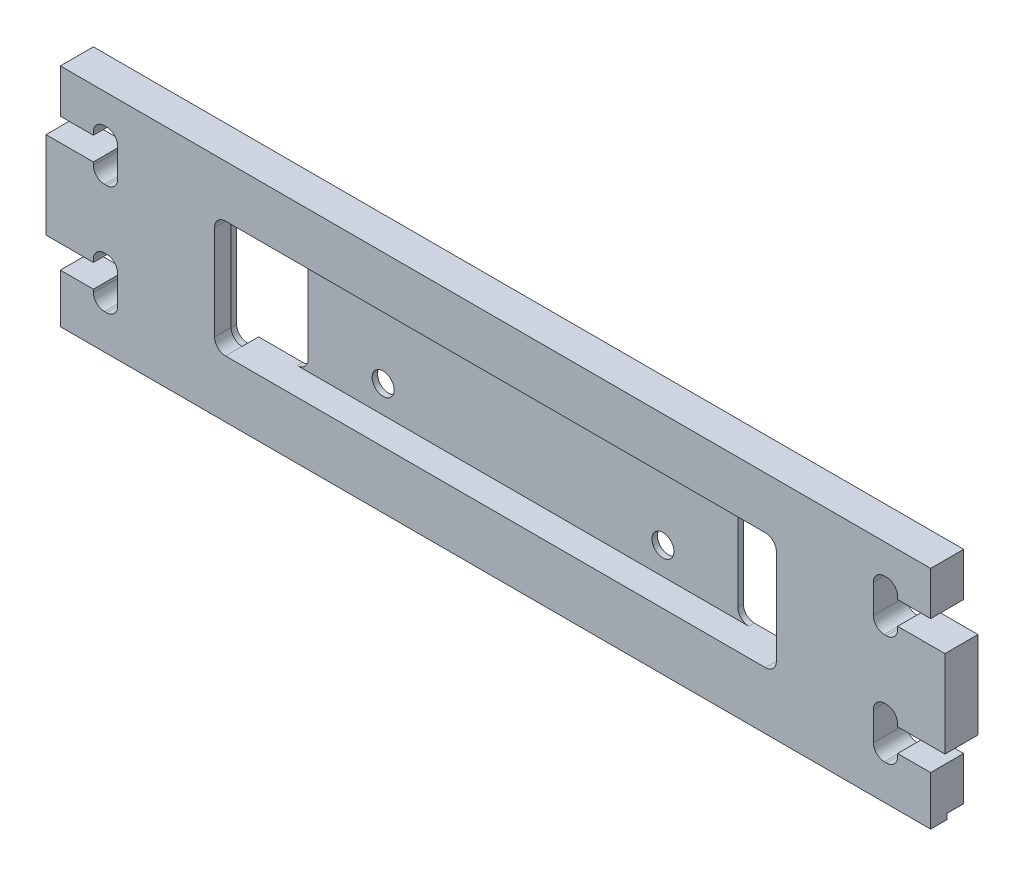
from build123d import *

# Parameters (mm, degrees)
SKETCH1_W                          = 1.3
SKETCH1_H                          = 7.9
BASE_SHAPE_DEPTH                   = 3
SKETCH4_W                          = 79
SKETCH4_H                          = 1.5
FLOOR_LIP_DEPTH                    = 0.5
NAIL_CUTOUT_DEPTH                  = 1.5
MILL_FILLETS_R                     = 1
LED_STRIP_POCKET_DEPTH             = 2.5
LED_STRIP_CUTS_REACH               = 2.5
SKETCH9_R                          = 1
LED_STRIP_CUT_FILLETS_R            = 1
LED_PCB_PADS_CLEARANCE_SLOTS_DEPTH = 1.5


with BuildPart() as part:
    # Sketch1 → Base shape (new body)
    with BuildSketch(Plane.XY):
        Polygon((39.5, 10), (-39.5, 10), (-39.5, 6.05), (-36.5, 6.05), (-36.5, 7.3), (-34.3, 7.3), (-34.3, 2.7), (-36.5, 2.7), (-36.5, 3.95), (-39.5, 3.95), (-39.5, -3.95), (-36.5, -3.95), (-36.5, -2.7), (-34.3, -2.7), (-34.3, -7.3), (-36.5, -7.3), (-36.5, -6.05), (-39.5, -6.05), (-39.5, -10), (39.5, -10), (39.5, -6.05), (36.5, -6.05), (36.5, -7.3), (34.3, -7.3), (34.3, -2.7), (36.5, -2.7), (36.5, -3.95), (39.5, -3.95), (39.5, 3.95), (36.5, 3.95), (36.5, 2.7), (34.3, 2.7), (34.3, 7.3), (36.5, 7.3), (36.5, 6.05), (39.5, 6.05), align=None)
        with Locations((-40.15, 0)):
            Rectangle(SKETCH1_W, SKETCH1_H)
        with Locations((40.15, 0)):
            Rectangle(SKETCH1_W, SKETCH1_H)
    extrude(amount=BASE_SHAPE_DEPTH)

    # Sketch4 → Floor lip (add)
    with BuildSketch(Plane.XZ.offset(10)):
        with Locations((0, 2.25)):
            Rectangle(SKETCH4_W, SKETCH4_H)
    extrude(amount=FLOOR_LIP_DEPTH)

    # Sketch6 → Nail cutout (cut)
    with BuildSketch(Plane(origin=(0, 0, 0), x_dir=(-1, 0, 0), z_dir=(0, 0, -1))):
        with BuildLine():
            Line((-4, -9), (4, -9))
            ThreePointArc((4, -9), (5, -10), (4, -11))
            Line((4, -11), (-4, -11))
            ThreePointArc((-4, -11), (-5, -10), (-4, -9))
        make_face()
    extrude(amount=-NAIL_CUTOUT_DEPTH, mode=Mode.SUBTRACT)

    # Mill fillets
    mill_fillets_edges = [part.edges().sort_by_distance(p)[0] for p in [
        (36.5, -2.7, 1.5),
        (34.3, -2.7, 1.5),
        (34.3, -7.3, 1.5),
        (36.5, -7.3, 1.5),
        (-36.5, -7.3, 1.5),
        (-34.3, -7.3, 1.5),
        (-34.3, -2.7, 1.5),
        (-36.5, -2.7, 1.5),
        (-36.5, 2.7, 1.5),
        (-34.3, 2.7, 1.5),
        (-34.3, 7.3, 1.5),
        (-36.5, 7.3, 1.5),
        (36.5, 7.3, 1.5),
        (34.3, 7.3, 1.5),
        (34.3, 2.7, 1.5),
        (36.5, 2.7, 1.5),
    ]]
    fillet(mill_fillets_edges, radius=MILL_FILLETS_R)

    # Sketch8 → Led strip pocket (cut)
    with BuildSketch(Plane.XY.offset(3)):
        with BuildLine():
            Line((-24.5, 5.3), (24.5, 5.3))
            ThreePointArc((24.5, 5.3), (25.207106781, 5.007106781), (25.5, 4.3))
            Line((25.5, 4.3), (25.5, -4.3))
            ThreePointArc((25.5, -4.3), (25.207106781, -5.007106781), (24.5, -5.3))
            Line((24.5, -5.3), (-24.5, -5.3))
            ThreePointArc((-24.5, -5.3), (-25.207106781, -5.007106781), (-25.5, -4.3))
            Line((-25.5, -4.3), (-25.5, 4.3))
            ThreePointArc((-25.5, 4.3), (-25.207106781, 5.007106781), (-24.5, 5.3))
        make_face()
    extrude(amount=-LED_STRIP_POCKET_DEPTH, mode=Mode.SUBTRACT)

    # Sketch9 → Led strip cuts (cut, up to next)
    with BuildSketch(Plane.XY.offset(0.5), mode=Mode.PRIVATE) as led_strip_cuts_sk1:
        with BuildLine():
            Line((-19.5, -5.3), (-19.5, 5.3))
            Line((-19.5, 5.3), (-24.5, 5.3))
            ThreePointArc((-24.5, 5.3), (-25.207106781, 5.007106781), (-25.5, 4.3))
            Line((-25.5, 4.3), (-25.5, -4.3))
            ThreePointArc((-25.5, -4.3), (-25.207106781, -5.007106781), (-24.5, -5.3))
            Line((-24.5, -5.3), (-19.5, -5.3))
        make_face()
    led_strip_cuts_tool1 = extrude(led_strip_cuts_sk1.sketch, amount=-LED_STRIP_CUTS_REACH, mode=Mode.PRIVATE) & part.part
    add(led_strip_cuts_tool1.solids().sort_by_distance((-22.481135, 0, 0.5))[0], mode=Mode.SUBTRACT)
    # Sketch9 → Led strip cuts (cut, up to next)
    with BuildSketch(Plane.XY.offset(0.5), mode=Mode.PRIVATE) as led_strip_cuts_sk2:
        with BuildLine():
            Line((24.5, 5.3), (19.5, 5.3))
            Line((19.5, 5.3), (19.5, -5.3))
            Line((19.5, -5.3), (24.5, -5.3))
            ThreePointArc((24.5, -5.3), (25.207106781, -5.007106781), (25.5, -4.3))
            Line((25.5, -4.3), (25.5, 4.3))
            ThreePointArc((25.5, 4.3), (25.207106781, 5.007106781), (24.5, 5.3))
        make_face()
    led_strip_cuts_tool2 = extrude(led_strip_cuts_sk2.sketch, amount=-LED_STRIP_CUTS_REACH, mode=Mode.PRIVATE) & part.part
    add(led_strip_cuts_tool2.solids().sort_by_distance((22.481135, 0, 0.5))[0], mode=Mode.SUBTRACT)
    # Sketch9 → Led strip cuts (cut, up to next)
    with BuildSketch(Plane.XY.offset(0.5), mode=Mode.PRIVATE) as led_strip_cuts_sk3:
        with Locations((-12.7, -2.828)):
            Circle(SKETCH9_R)
    led_strip_cuts_tool3 = extrude(led_strip_cuts_sk3.sketch, amount=-LED_STRIP_CUTS_REACH, mode=Mode.PRIVATE) & part.part
    add(led_strip_cuts_tool3.solids().sort_by_distance((-12.7, -2.828, 0.5))[0], mode=Mode.SUBTRACT)
    # Sketch9 → Led strip cuts (cut, up to next)
    with BuildSketch(Plane.XY.offset(0.5), mode=Mode.PRIVATE) as led_strip_cuts_sk4:
        with Locations((12.7, -2.828)):
            Circle(SKETCH9_R)
    led_strip_cuts_tool4 = extrude(led_strip_cuts_sk4.sketch, amount=-LED_STRIP_CUTS_REACH, mode=Mode.PRIVATE) & part.part
    add(led_strip_cuts_tool4.solids().sort_by_distance((12.7, -2.828, 0.5))[0], mode=Mode.SUBTRACT)

    # Led strip cut fillets
    led_strip_cut_fillets_edges = [part.edges().sort_by_distance(p)[0] for p in [
        (-19.5, 5.3, 0.25),
        (-19.5, -5.3, 0.25),
        (19.5, 5.3, 0.25),
        (19.5, -5.3, 0.25),
    ]]
    fillet(led_strip_cut_fillets_edges, radius=LED_STRIP_CUT_FILLETS_R)

    # Sketch23 → LED PCB pads clearance slots (cut)
    with BuildSketch(Plane(origin=(0, 0, 0), x_dir=(-1, 0, 0), z_dir=(0, 0, -1))):
        with BuildLine():
            Line((-26.5, -5.3), (-26.5, 5.3))
            ThreePointArc((-26.5, 5.3), (-25.5, 6.3), (-24.5, 5.3))
            Line((-24.5, 5.3), (-24.5, -5.3))
            ThreePointArc((-24.5, -5.3), (-25.5, -6.3), (-26.5, -5.3))
        make_face()
        with BuildLine():
            Line((26.5, -5.3), (26.5, 5.3))
            ThreePointArc((26.5, 5.3), (25.5, 6.3), (24.5, 5.3))
            Line((24.5, 5.3), (24.5, -5.3))
            ThreePointArc((24.5, -5.3), (25.5, -6.3), (26.5, -5.3))
        make_face()
    extrude(amount=-LED_PCB_PADS_CLEARANCE_SLOTS_DEPTH, mode=Mode.SUBTRACT)


solid = part.part
